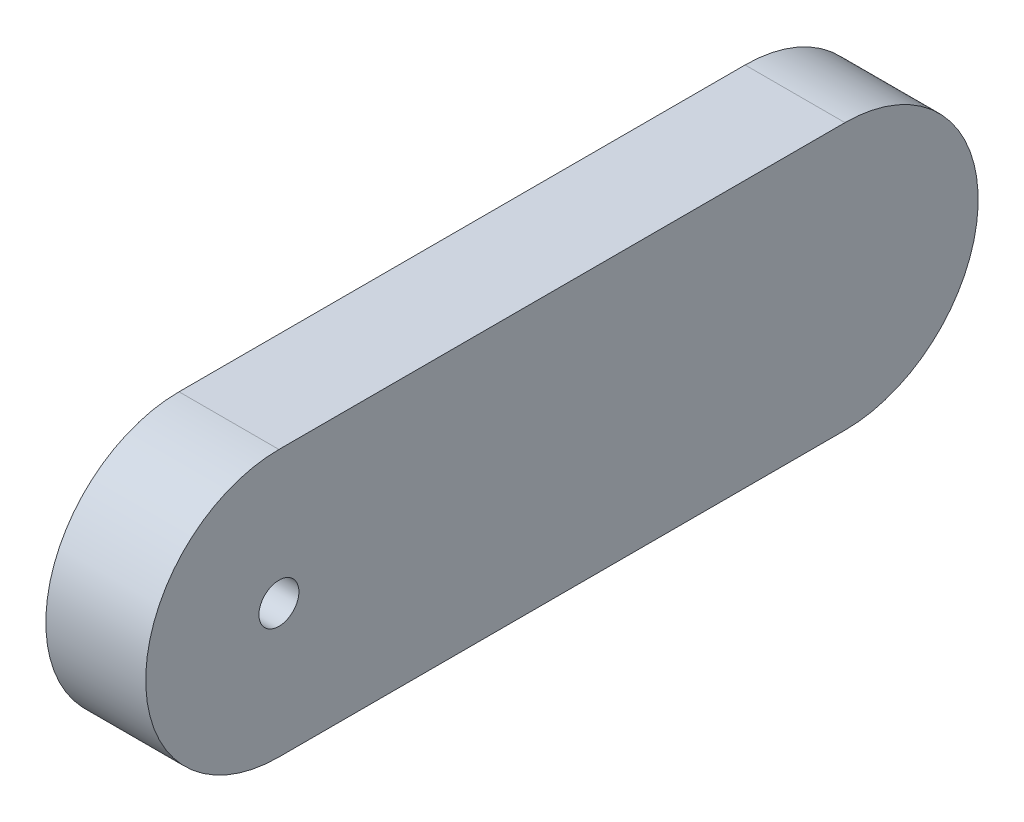
from build123d import *

# Parameters (mm, degrees)
SKETCH2_W               = 250
SKETCH2_H               = 80
BOSS_EXTRUDE1_DEPTH     = 30
SKETCH11_R              = 6
CUT_EXTRUDE2_DEPTH      = 265.196896272
CUT_EXTRUDE_THIN2_DEPTH = 265.196896272
SKETCH15_W              = 40
SKETCH15_H              = 20
CUT_EXTRUDE3_DEPTH      = 25


with BuildPart() as part:
    # Sketch2 → Boss-Extrude1 (new body)
    with BuildSketch(Plane(origin=(0, 0, 0), x_dir=(0, 0, -1), z_dir=(1, 0, 0))):
        with Locations((125, 40)):
            Rectangle(SKETCH2_W, SKETCH2_H)
    extrude(amount=BOSS_EXTRUDE1_DEPTH)

    # Sketch11 → Cut-Extrude2 (cut, through all)
    with BuildSketch(Plane(origin=(30, 0, 0), x_dir=(0, 0, -1), z_dir=(1, 0, 0))):
        with Locations((40, 40)):
            Circle(SKETCH11_R)
    extrude(amount=-CUT_EXTRUDE2_DEPTH, mode=Mode.SUBTRACT)

    # Sketch14 → Cut-Extrude-Thin2 (cut, through all)
    with BuildSketch(Plane.ZY):
        with BuildLine():
            ThreePointArc((-40, 0), (0, 40), (-40, 80))
            Line((-40, 80), (-40, 90))
            ThreePointArc((-40, 90), (10, 40), (-40, -10))
            Line((-40, -10), (-40, 0))
        make_face()
        with BuildLine():
            ThreePointArc((-210, 80), (-250, 40), (-210, 0))
            Line((-210, 0), (-210, -10))
            ThreePointArc((-210, -10), (-260, 40), (-210, 90))
            Line((-210, 90), (-210, 80))
        make_face()
    extrude(amount=-CUT_EXTRUDE_THIN2_DEPTH, mode=Mode.SUBTRACT)


with BuildPart() as cut_extrude_thin2_kept_piece:
    # of the separate pieces the step leaves, the one the design keeps (cut_extrude_thin2_pieces_kept)
    add(part.part.solids().sort_by_distance((0, 0, -40))[0])

    # Sketch15 → Cut-Extrude3 (cut)
    with BuildSketch(Plane.ZY):
        with Locations((-200, 40)):
            Rectangle(SKETCH15_W, SKETCH15_H)
    extrude(amount=-CUT_EXTRUDE3_DEPTH, mode=Mode.SUBTRACT)


solid = cut_extrude_thin2_kept_piece.part
